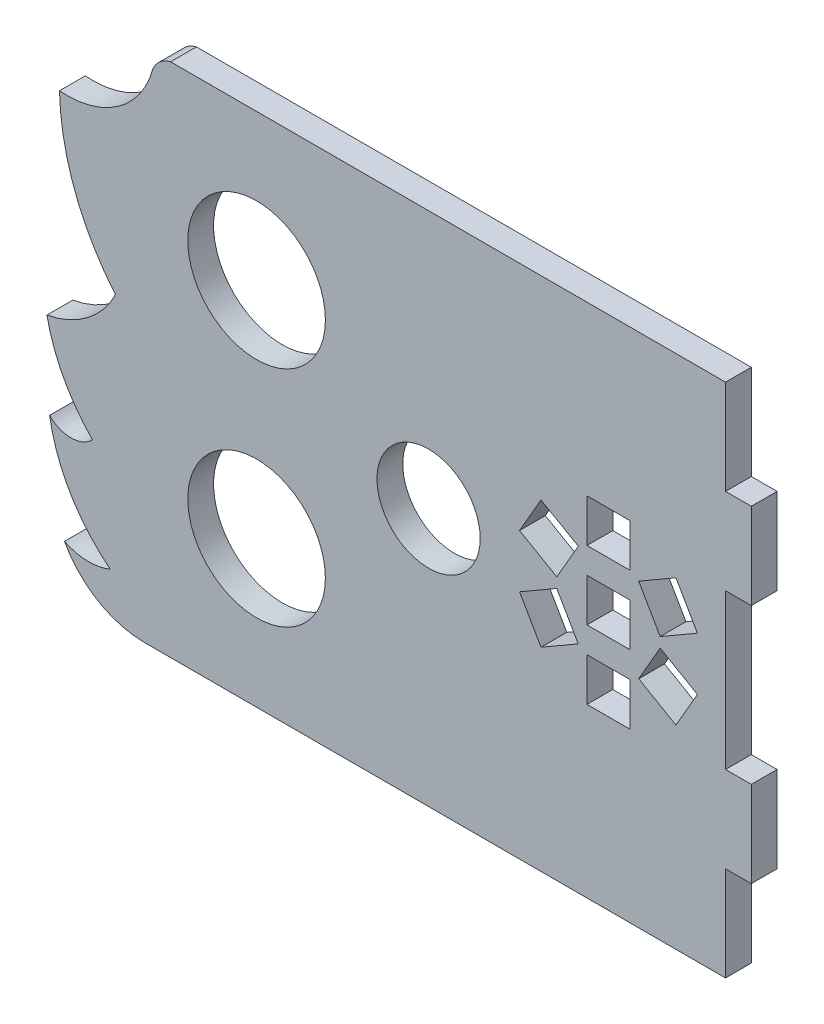
from build123d import *

# Parameters (mm, degrees)
MODEL_R                 = 8
MODEL_R_2               = 6
MODEL_W                 = 5
MODEL_H                 = 5
SALIENTE_EXTRUIR1_DEPTH = 3


with BuildPart() as part:
    # Model → Saliente-Extruir1 (new body)
    with BuildSketch(Plane.XY):
        with BuildLine():
            Line((76.347655659, 34.880000028), (76.347655659, 24.880000028))
            Line((76.347655659, 24.880000028), (73.347655659, 24.880000028))
            Line((73.347655659, 24.880000028), (73.347655659, 6.880000028))
            Line((73.347655659, 6.880000028), (76.347655659, 6.880000028))
            Line((76.347655659, 6.880000028), (76.347655659, -3.119999972))
            Line((76.347655659, -3.119999972), (73.347655659, -3.119999972))
            Line((73.347655659, -3.119999972), (73.347655659, -14.119999972))
            Line((73.347655659, -14.119999972), (61.82755788, -14.119999972))
            Line((61.82755788, -14.119999972), (5.822580598, -14.119999972))
            ThreePointArc((5.822580598, -14.119999972), (0.393738877, -12.632215144), (-3.517289733, -8.583798005))
            ThreePointArc((-3.517289733, -8.583798005), (-0.871613495, -9.225522901), (1.80545298, -8.730822292))
            ThreePointArc((1.80545298, -8.730822292), (-2.833232138, -3.402025371), (-5.249801899, 3.236774734))
            ThreePointArc((-5.249801899, 3.236774734), (-2.74505386, 2.21277877), (-0.249855047, 3.259828604))
            ThreePointArc((-0.249855047, 3.259828604), (-3.624986156, 7.837335992), (-5.559793418, 13.185382809))
            ThreePointArc((-5.559793418, 13.185382809), (-0.86111803, 15.262797511), (2.412456901, 19.222205222))
            ThreePointArc((2.412456901, 19.222205222), (-2.310766872, 27.309140745), (-4.095322699, 36.502765137))
            ThreePointArc((-4.095322699, 36.502765137), (2.717491313, 38.336145621), (6.755388207, 44.121567597))
            ThreePointArc((6.755388207, 44.121567597), (7.57877424, 45.247904396), (8.822580598, 45.880000028))
            Line((8.822580598, 45.880000028), (11.313037594, 45.880000028))
            Line((11.313037594, 45.880000028), (73.347655659, 45.880000028))
            Line((73.347655659, 45.880000028), (73.347655659, 34.880000028))
            Line((73.347655659, 34.880000028), (76.347655659, 34.880000028))
        make_face()
        with Locations((18.822580598, 28.880000028)):
            Circle(MODEL_R, mode=Mode.SUBTRACT)
        with Locations((38.822580598, 15.880000028)):
            Circle(MODEL_R_2, mode=Mode.SUBTRACT)
        with Locations((18.822580598, 2.880000028)):
            Circle(MODEL_R, mode=Mode.SUBTRACT)
        Polygon((53.725434944, 16.464936518), (56.225434944, 20.795063537), (51.895307925, 23.295063537), (49.395307925, 18.964936518), align=None, mode=Mode.SUBTRACT)
        Polygon((49.395307925, 12.795063537), (51.895307925, 8.464936518), (56.225434944, 10.964936518), (53.725434944, 15.295063537), align=None, mode=Mode.SUBTRACT)
        with Locations((59.738574665, 23.880000028)):
            Rectangle(MODEL_W, MODEL_H, mode=Mode.SUBTRACT)
        Polygon((65.751714386, 15.295063537), (63.251714386, 10.964936518), (67.581841405, 8.464936518), (70.081841405, 12.795063537), align=None, mode=Mode.SUBTRACT)
        Polygon((70.081841405, 18.964936518), (67.581841405, 23.295063537), (63.251714386, 20.795063537), (65.751714386, 16.464936518), align=None, mode=Mode.SUBTRACT)
        with Locations((59.738574665, 7.880000028)):
            Rectangle(MODEL_W, MODEL_H, mode=Mode.SUBTRACT)
        with Locations((59.738574665, 15.880000028)):
            Rectangle(MODEL_W, MODEL_H, mode=Mode.SUBTRACT)
    extrude(amount=SALIENTE_EXTRUIR1_DEPTH)


solid = part.part
